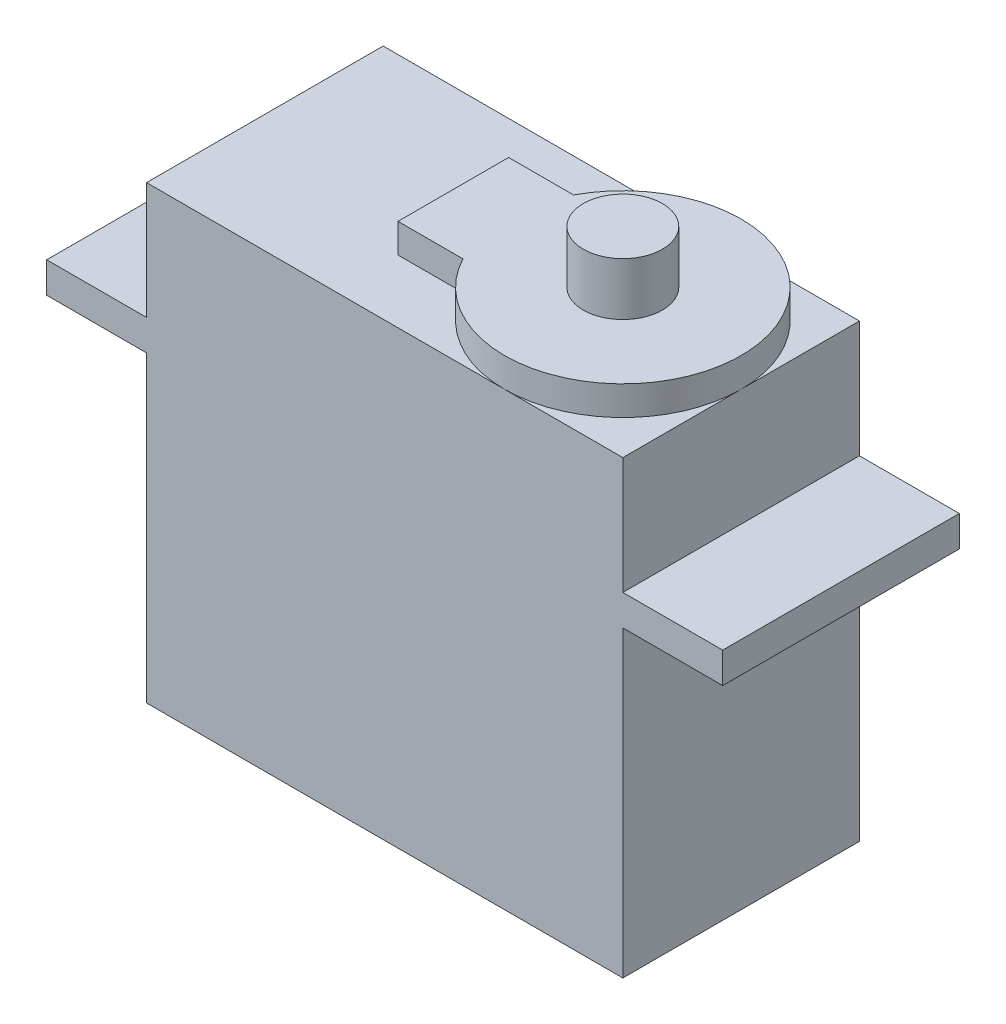
from build123d import *

# Parameters (mm, degrees)
SKETCH1_W           = 23.622
SKETCH1_H           = 22.352
BOSS_EXTRUDE1_DEPTH = 5.8674
SKETCH3_W           = 4.953
SKETCH3_H           = 1.524
BOSS_EXTRUDE2_DEPTH = 11.7348
SKETCH4_R           = 5.8674
BOSS_EXTRUDE3_DEPTH = 1.4478
SKETCH5_R           = 1.96215
BOSS_EXTRUDE4_DEPTH = 2.6162
SKETCH6_W           = 3.220759804
SKETCH6_H           = 5.4864
BOSS_EXTRUDE5_DEPTH = 1.4478


with BuildPart() as part:
    # Sketch1 → Boss-Extrude1 (new body, symmetric)
    with BuildSketch(Plane.XY):
        Rectangle(SKETCH1_W, SKETCH1_H)
    extrude(amount=BOSS_EXTRUDE1_DEPTH, both=True)

    # Sketch3 → Boss-Extrude2 (add)
    with BuildSketch(Plane.XY.offset(5.8674)):
        with Locations((-14.2875, 4.6228)):
            Rectangle(SKETCH3_W, SKETCH3_H)
        with Locations((14.2875, 4.6228)):
            Rectangle(SKETCH3_W, SKETCH3_H)
    extrude(amount=-BOSS_EXTRUDE2_DEPTH)

    # Sketch4 → Boss-Extrude3 (add)
    with BuildSketch(Plane(origin=(0, 11.176, 0), x_dir=(1, 0, 0), z_dir=(0, 1, 0))):
        with Locations((5.9436, 0)):
            Circle(SKETCH4_R)
    extrude(amount=BOSS_EXTRUDE3_DEPTH)

    # Sketch5 → Boss-Extrude4 (add)
    with BuildSketch(Plane(origin=(0, 12.6238, 0), x_dir=(1, 0, 0), z_dir=(0, 1, 0))):
        with Locations((5.9436, 0)):
            Circle(SKETCH5_R)
    extrude(amount=BOSS_EXTRUDE4_DEPTH)

    # Sketch6 → Boss-Extrude5 (add)
    with BuildSketch(Plane(origin=(0, 12.6238, 0), x_dir=(1, 0, 0), z_dir=(0, 1, 0))):
        with Locations((-0.853420098, 0)):
            Rectangle(SKETCH6_W, SKETCH6_H)
    extrude(amount=-BOSS_EXTRUDE5_DEPTH)


solid = part.part
